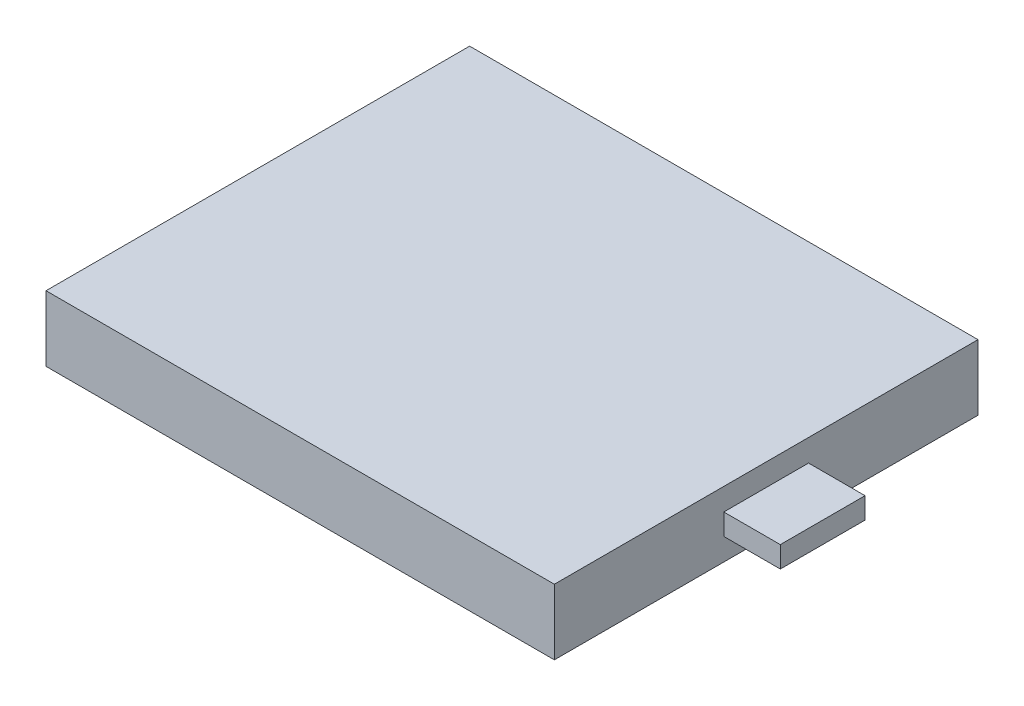
from build123d import *

# Parameters (mm, degrees)
SKETCH1_W           = 36
SKETCH1_H           = 30
BOSS_EXTRUDE1_DEPTH = 4.64
SKETCH2_W           = 6
SKETCH2_H           = 1.5
BOSS_EXTRUDE2_DEPTH = 4


with BuildPart() as part:
    # Sketch1 → Boss-Extrude1 (new body)
    with BuildSketch(Plane(origin=(0, 0, 0), x_dir=(1, 0, 0), z_dir=(0, 1, 0))):
        with Locations((18, 15)):
            Rectangle(SKETCH1_W, SKETCH1_H)
    extrude(amount=BOSS_EXTRUDE1_DEPTH)

    # Sketch2 → Boss-Extrude2 (add)
    with BuildSketch(Plane(origin=(36, 0, 0), x_dir=(0, 0, -1), z_dir=(1, 0, 0))):
        with Locations((15, 2.32)):
            Rectangle(SKETCH2_W, SKETCH2_H)
    extrude(amount=BOSS_EXTRUDE2_DEPTH)


solid = part.part
